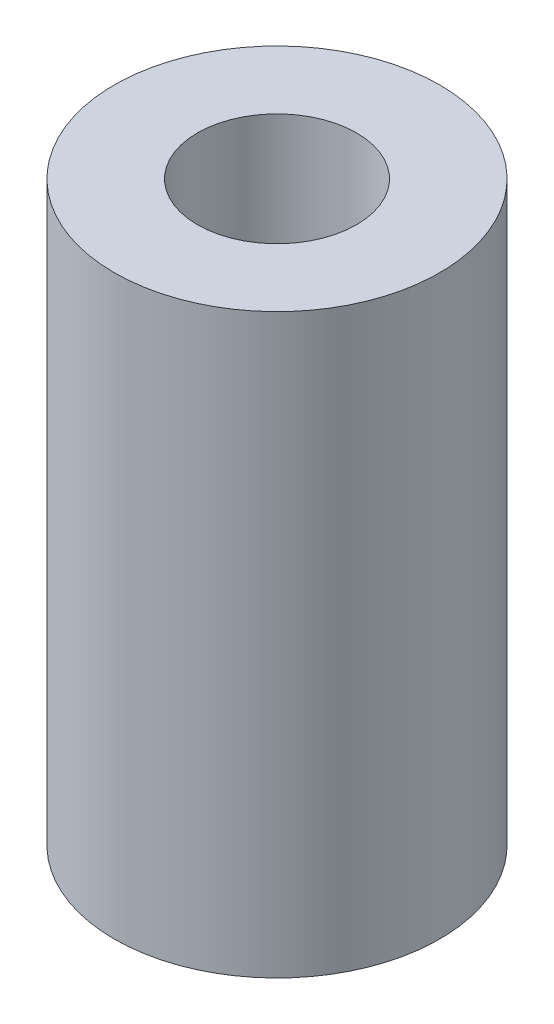
from build123d import *

# Parameters (mm, degrees)
SKETCH1_R           = 32.4612
SKETCH1_R_2         = 15.875
BOSS_EXTRUDE1_DEPTH = 115.146666667


with BuildPart() as part:
    # Sketch1 → Boss-Extrude1 (new body)
    with BuildSketch(Plane(origin=(0, 0, 0), x_dir=(1, 0, 0), z_dir=(0, 1, 0))):
        Circle(SKETCH1_R)
        Circle(SKETCH1_R_2, mode=Mode.SUBTRACT)
    extrude(amount=BOSS_EXTRUDE1_DEPTH)


solid = part.part
